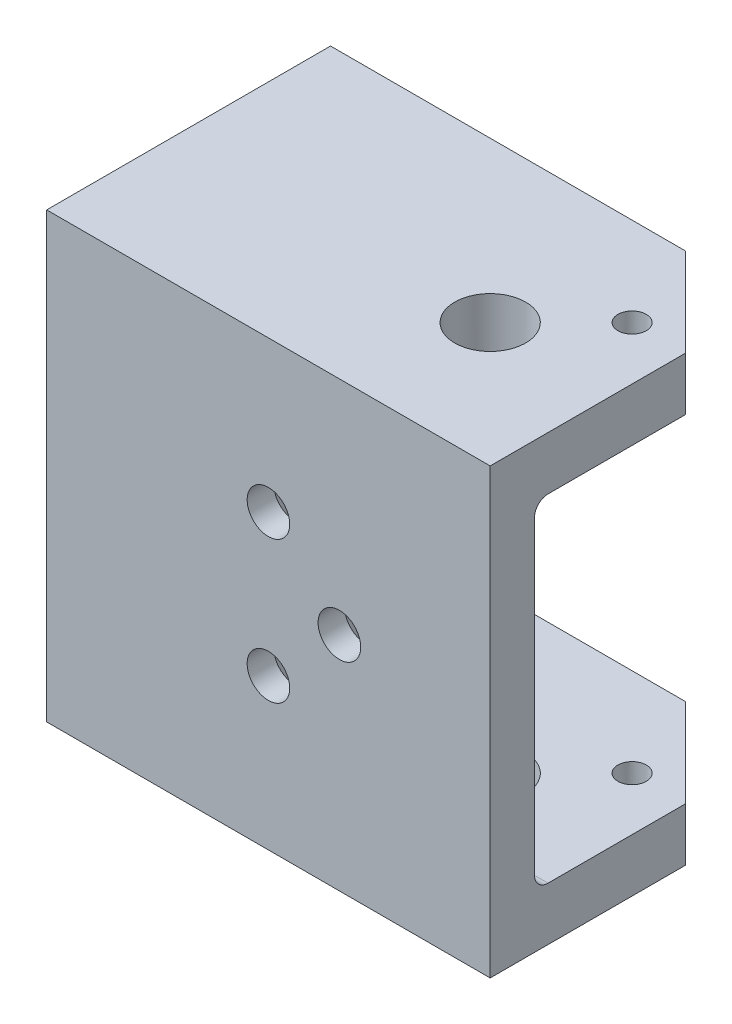
from build123d import *

# Parameters (mm, degrees)
SKETCH1_W                                       = 25
SKETCH1_H                                       = 25
BOSS_EXTRUDE1_DEPTH                             = 2.5
SKETCH2_W                                       = 25
SKETCH2_H                                       = 3
BOSS_EXTRUDE2_DEPTH                             = 13.5
SKETCH10_R                                      = 2
CUT_EXTRUDE1_DEPTH                              = 32.04029639
SKETCH10_3_R                                    = 0.8
CUT_EXTRUDE2_DEPTH                              = 32.04029639
FILLET1_R                                       = 0.762
CHAMFER1_SIZE                                   = 5
CSK_FOR_M2_FLAT_HEAD_MACHINE_SCREW1_D           = 2.4
CSK_FOR_M2_FLAT_HEAD_MACHINE_SCREW1_CSINK_D     = 4.4
CSK_FOR_M2_FLAT_HEAD_MACHINE_SCREW1_CSINK_ANGLE = 90


with BuildPart() as part:
    # Sketch1 → Boss-Extrude1 (new body)
    with BuildSketch(Plane.XY):
        Rectangle(SKETCH1_W, SKETCH1_H)
    extrude(amount=BOSS_EXTRUDE1_DEPTH)

    # Sketch2 → Boss-Extrude2 (add)
    with BuildSketch(Plane(origin=(0, 0, 0), x_dir=(-1, 0, 0), z_dir=(0, 0, -1))):
        with Locations((0, 11)):
            Rectangle(SKETCH2_W, SKETCH2_H)
        with Locations((0, -11)):
            Rectangle(SKETCH2_W, SKETCH2_H)
    extrude(amount=BOSS_EXTRUDE2_DEPTH)

    # Sketch10 → Cut-Extrude1 (cut, through all)
    with BuildSketch(Plane.XZ.offset(12.5)):
        with Locations((5.5, -4.5)):
            Circle(SKETCH10_R)
    extrude(amount=-CUT_EXTRUDE1_DEPTH, mode=Mode.SUBTRACT)

    # Sketch10_3 → Cut-Extrude2 (cut, through all)
    with BuildSketch(Plane.XZ.offset(12.5)):
        with Locations((9.5, -8.5)):
            Circle(SKETCH10_3_R)
    extrude(amount=-CUT_EXTRUDE2_DEPTH, mode=Mode.SUBTRACT)

    # Fillet1
    fillet1_edges = [part.edges().sort_by_distance(p)[0] for p in [
        (0, -9.5, 0),
        (0, 9.5, 0),
    ]]
    fillet(fillet1_edges, radius=FILLET1_R)

    # Chamfer1
    chamfer1_edges = [part.edges().sort_by_distance(p)[0] for p in [
        (12.5, -11, -13.5),
        (12.5, 11, -13.5),
    ]]
    chamfer(chamfer1_edges, length=CHAMFER1_SIZE)

    # CSK for M2 Flat Head Machine Screw1 (through all)
    with Locations(Plane(origin=(0, 0, 0), x_dir=(-1, 0, 0), z_dir=(0, 0, -1))):
        with Locations((0, 4), (0, -4), (-4, 0)):
            CounterSinkHole(CSK_FOR_M2_FLAT_HEAD_MACHINE_SCREW1_D / 2, CSK_FOR_M2_FLAT_HEAD_MACHINE_SCREW1_CSINK_D / 2, counter_sink_angle=CSK_FOR_M2_FLAT_HEAD_MACHINE_SCREW1_CSINK_ANGLE)


solid = part.part
